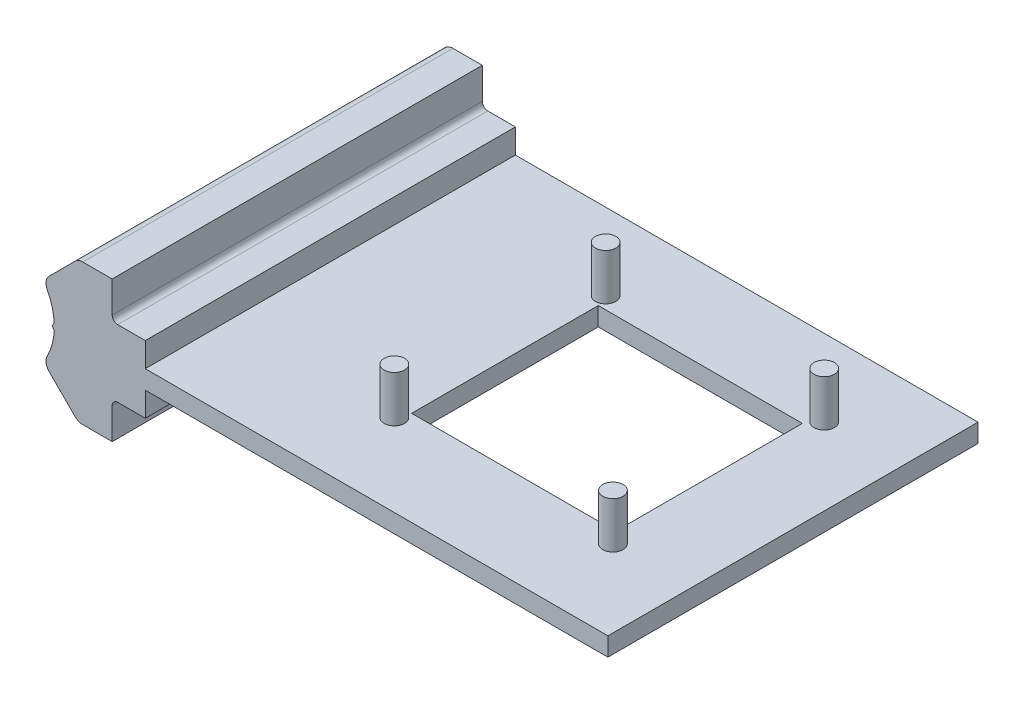
from build123d import *

# Parameters (mm, degrees)
BOSS_EXTRUDE1_DEPTH = 50.8
SKETCH3_R           = 1.397
BOSS_EXTRUDE2_DEPTH = 6.35
SKETCH4_W           = 28.015
SKETCH4_H           = 25.618
CUT_EXTRUDE1_DEPTH  = 11.939


with BuildPart() as part:
    # Sketch1 → Boss-Extrude1 (new body)
    with BuildSketch(Plane.XY.offset(438.358905075)):
        with BuildLine():
            Line((42.509706517, 19.30434166), (42.509706517, 15.95534166))
            Line((42.509706517, 15.95534166), (106.009706517, 15.95534166))
            Line((106.009706517, 15.95534166), (106.009706517, 13.41534166))
            Line((106.009706517, 13.41534166), (42.509706517, 13.41534166))
            Line((42.509706517, 13.41534166), (42.509706517, 10.06634166))
            Line((42.509706517, 10.06634166), (38.725206517, 10.06634166))
            ThreePointArc((38.725206517, 10.06634166), (38.189219577, 9.8443286), (37.967206517, 9.30834166))
            Line((37.967206517, 9.30834166), (37.967206517, 5.01634166))
            Line((37.967206517, 5.01634166), (33.928999082, 5.01634166))
            ThreePointArc((33.928999082, 5.01634166), (33.3534432, 5.130826843), (32.865510483, 5.456853061))
            Line((32.865510483, 5.456853061), (29.322559963, 8.999803581))
            ThreePointArc((29.322559963, 8.999803581), (28.898807275, 9.839396326), (29.056588326, 10.766535722))
            ThreePointArc((29.056588326, 10.766535722), (29.726160528, 12.451998876), (30.017474414, 14.24204055))
            Line((30.017474414, 14.24204055), (29.707071635, 14.68534166))
            Line((29.707071635, 14.68534166), (30.017474414, 15.128642769))
            ThreePointArc((30.017474414, 15.128642769), (29.726160528, 16.918684443), (29.056588326, 18.604147597))
            ThreePointArc((29.056588326, 18.604147597), (28.898807275, 19.531286993), (29.322559963, 20.370879739))
            Line((29.322559963, 20.370879739), (32.865510483, 23.913830259))
            ThreePointArc((32.865510483, 23.913830259), (33.3534432, 24.239856477), (33.928999082, 24.35434166))
            Line((33.928999082, 24.35434166), (37.967206517, 24.35434166))
            Line((37.967206517, 24.35434166), (37.967206517, 20.06234166))
            ThreePointArc((37.967206517, 20.06234166), (38.189219577, 19.526354719), (38.725206517, 19.30434166))
            Line((38.725206517, 19.30434166), (42.509706517, 19.30434166))
        make_face()
    extrude(amount=-BOSS_EXTRUDE1_DEPTH)

    # Sketch3 → Boss-Extrude2 (add)
    with BuildSketch(Plane(origin=(0, 15.95534166, 0), x_dir=(1, 0, 0), z_dir=(0, 1, 0))):
        with Locations((65.411874918, -398.072421398)):
            Circle(SKETCH3_R)
        with Locations((95.411874918, -398.072421398)):
            Circle(SKETCH3_R)
        with Locations((95.411874918, -427.072421398)):
            Circle(SKETCH3_R)
        with Locations((65.411874918, -427.072421398)):
            Circle(SKETCH3_R)
    extrude(amount=BOSS_EXTRUDE2_DEPTH)

    # Sketch4 → Cut-Extrude1 (cut, through all)
    with BuildSketch(Plane(origin=(0, 15.95534166, 0), x_dir=(1, 0, 0), z_dir=(0, 1, 0))):
        with Locations((80.094374918, -412.572421398)):
            Rectangle(SKETCH4_W, SKETCH4_H)
    extrude(amount=-CUT_EXTRUDE1_DEPTH, mode=Mode.SUBTRACT)


solid = part.part
